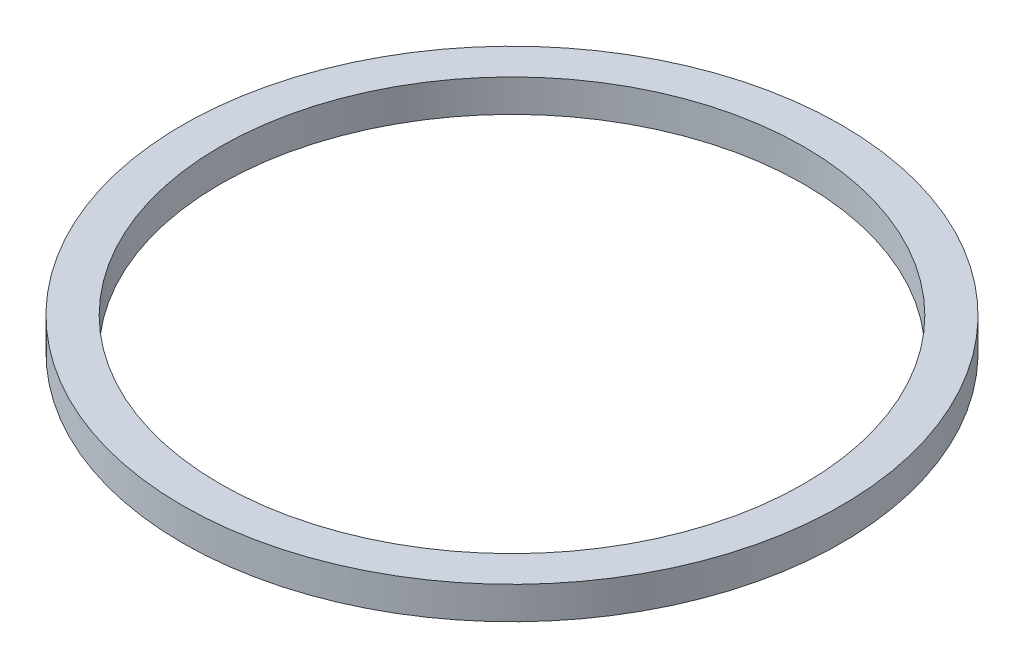
from build123d import *

# Parameters (mm, degrees)
SKETCH_1_W = 2.9
SKETCH_1_H = 2.5


with BuildPart() as part:
    # 草图1 → 旋转1 (revolve)
    with BuildSketch(Plane.XY, mode=Mode.PRIVATE) as revolve_1_sk:
        with Locations((23.95, 1.25)):
            Rectangle(SKETCH_1_W, SKETCH_1_H)
    revolve(revolve_1_sk.sketch.rotate(Axis((0, 77.144142266, 0), (0, -1, 0)), 90), axis=Axis((0, 77.144142266, 0), (0, -1, 0)))  # turned: the seam where the file's is


solid = part.part
